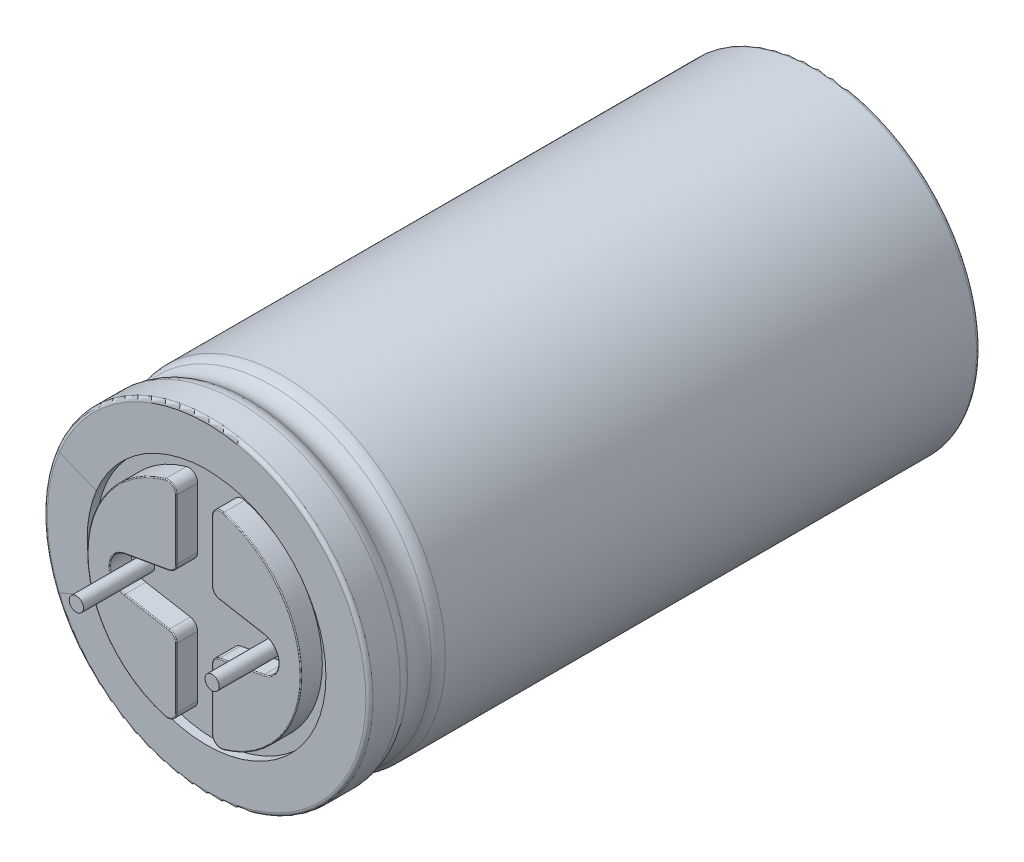
from build123d import *

# Parameters (mm, degrees)
SZKIC2_R                      = 6.7
WYTNIJ_WYCI_GNI_CIE1_DEPTH    = 0.2
WYTNIJ_WYCI_GNI_CIE2_DEPTH    = 0.2
SZYK_KO_OWY1_COUNT            = 4
SZKIC4_R                      = 6.7
WYTNIJ_WYCI_GNI_CIE3_DEPTH    = 0.5
DODANIE_WYCI_GNI_CIE1_DEPTH   = 1.2
ZAOKR_GLENIE1_R               = 0.05
SZKIC11_R                     = 0.4
DODANIE_WYCI_GNI_CIE2_DEPTH   = 4
DODANIE_WYCI_GNI_CIE2_2_DEPTH = 4
SZYK_KO_OWY3_COUNT            = 2
SZYK_KO_OWY3_ANGLE            = 180


with BuildPart() as part:
    # Szkic1 → Obrót1 (revolve)
    with BuildSketch(Plane(origin=(0, 0, 0), x_dir=(1, 0, 0), z_dir=(0, 1, 0))):
        with BuildLine():
            Line((0, 0.72), (0, 35))
            Line((0, 35), (8.94, 35))
            ThreePointArc((8.94, 35), (9.081421356, 34.941421356), (9.14, 34.8))
            Line((9.14, 34.8), (9.14, 4.983671378))
            ThreePointArc((9.14, 4.983671378), (9.090330433, 4.672428599), (8.946255865, 4.392104408))
            ThreePointArc((8.946255865, 4.392104408), (8.726134908, 3.72), (8.946255865, 3.047895592))
            ThreePointArc((8.946255865, 3.047895592), (9.090330433, 2.767571401), (9.14, 2.456328622))
            Line((9.14, 2.456328622), (9.14, 0.92))
            ThreePointArc((9.14, 0.92), (9.081421356, 0.778578644), (8.94, 0.72))
            Line((8.94, 0.72), (0, 0.72))
        make_face()
    revolve(axis=Axis((0, 0, -0.72), (0, 0, -1)))

    # Szkic2 → Wytnij-wyciągnięcie1 (cut)
    with BuildSketch(Plane(origin=(0, 0, -35), x_dir=(-1, 0, 0), z_dir=(0, 0, -1))):
        Circle(SZKIC2_R)
    extrude(amount=-WYTNIJ_WYCI_GNI_CIE1_DEPTH, mode=Mode.SUBTRACT)

    # Szkic3 → Wytnij-wyciągnięcie2 (cut)
    with BuildSketch(Plane(origin=(0, 0, -34.8), x_dir=(-1, 0, 0), z_dir=(0, 0, -1))):
        with BuildLine():
            Line((0.1, 0), (0.1, 6))
            ThreePointArc((0.1, 6), (0, 6.1), (-0.1, 6))
            Line((-0.1, 6), (-0.1, 0))
            ThreePointArc((-0.1, 0), (0, -0.1), (0.1, 0))
        make_face()
    wytnij_wyci_gni_cie2 = extrude(amount=-WYTNIJ_WYCI_GNI_CIE2_DEPTH, mode=Mode.SUBTRACT)

    # Szyk kołowy1: Wytnij-wyciągnięcie2 ×4 about axis
    szyk_ko_owy1_axis = Axis((0, 0, 0), (0, 0, 1))
    for i in range(1, SZYK_KO_OWY1_COUNT):
        add(wytnij_wyci_gni_cie2.rotate(szyk_ko_owy1_axis, i * 360 / SZYK_KO_OWY1_COUNT), mode=Mode.SUBTRACT)

    # Szkic4 → Wytnij-wyciągnięcie3 (cut)
    with BuildSketch(Plane.XY.offset(-0.72)):
        Circle(SZKIC4_R)
    extrude(amount=-WYTNIJ_WYCI_GNI_CIE3_DEPTH, mode=Mode.SUBTRACT)


with BuildPart() as body_2:
    # Szkic5 → Dodanie-wyciągnięcie1 (new body)
    with BuildSketch(Plane.XY.offset(-1.22)):
        with BuildLine():
            Line((1, -1.918885649), (1, -5.291502622))
            ThreePointArc((1, -5.291502622), (1.198488655, -5.69036464), (1.636363636, -5.772548315))
            ThreePointArc((1.636363636, -5.772548315), (6, 0), (1.636363636, 5.772548315))
            ThreePointArc((1.636363636, 5.772548315), (1.198488655, 5.69036464), (1, 5.291502622))
            Line((1, 5.291502622), (1, 1.918885649))
            ThreePointArc((1, 1.918885649), (1.116727205, 1.597790702), (1.412407859, 1.426617819))
            Line((1.412407859, 1.426617819), (3.909784266, 0.982244793))
            ThreePointArc((3.909784266, 0.982244793), (4.732680761, 0), (3.909784266, -0.982244793))
            Line((3.909784266, -0.982244793), (1.412407859, -1.426617819))
            ThreePointArc((1.412407859, -1.426617819), (1.116727205, -1.597790702), (1, -1.918885649))
        make_face()
    extrude(amount=DODANIE_WYCI_GNI_CIE1_DEPTH)

    # Zaokrąglenie1
    zaokr_glenie1_edges = [body_2.edges().sort_by_distance(p)[0] for p in [
        (1.198488655, 5.69036464, -0.02),
        (1, 3.605194136, -0.02),
        (1.116727205, 1.597790702, -0.02),
        (2.661096062, 1.204431306, -0.02),
        (4.732680761, 0, -0.02),
        (2.661096062, -1.204431306, -0.02),
        (1.116727205, -1.597790702, -0.02),
        (1, -3.605194136, -0.02),
        (1.198488655, -5.69036464, -0.02),
        (6, 0, -0.02),
    ]]
    fillet(zaokr_glenie1_edges, radius=ZAOKR_GLENIE1_R)


with BuildPart() as body_3:
    # Szkic11 → Dodanie-wyciągnięcie2 (new body)
    with BuildSketch(Plane.XY.offset(-1.22)):
        with Locations((-3.81, 0)):
            Circle(SZKIC11_R)
    extrude(amount=DODANIE_WYCI_GNI_CIE2_DEPTH)


with BuildPart() as body_4:
    # Szkic11 → Dodanie-wyci_gni_cie2 2 (new body)
    with BuildSketch(Plane.XY.offset(-1.22)):
        with Locations((3.81, 0)):
            Circle(SZKIC11_R)
    extrude(amount=DODANIE_WYCI_GNI_CIE2_2_DEPTH)


with BuildPart() as szyk_ko_owy3_1:
    # Szyk kołowy3: pattern copy
    add(body_2.part.rotate(Axis((0, 0, 0), (0, 0, 1)), 1 * SZYK_KO_OWY3_ANGLE / (SZYK_KO_OWY3_COUNT - 1)))


solid = Compound([part.part, body_2.part, body_3.part, body_4.part, szyk_ko_owy3_1.part])
